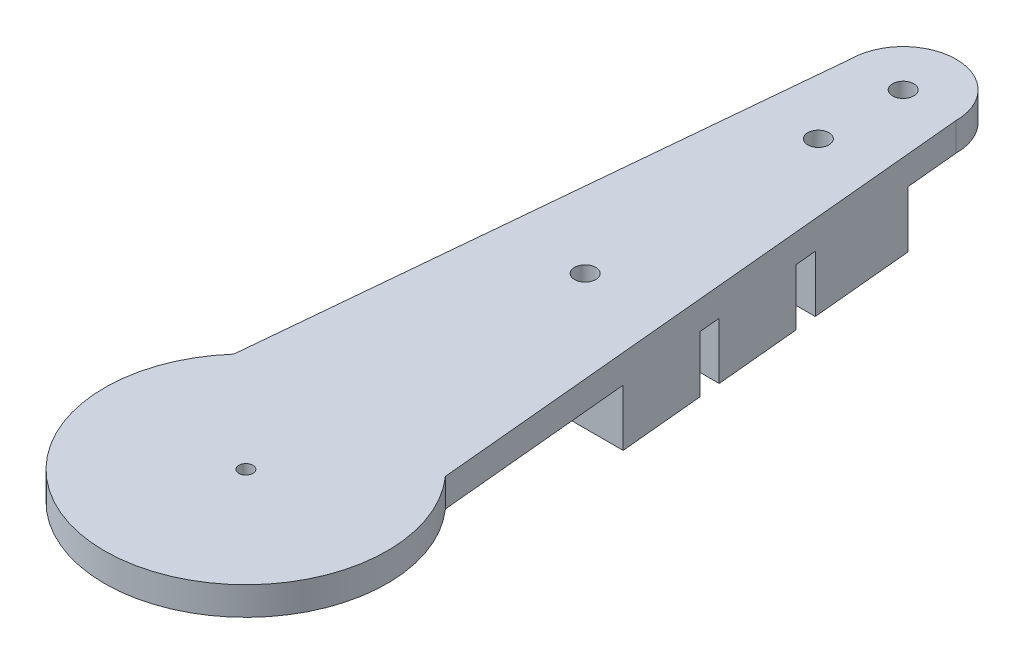
from build123d import *

# Parameters (mm, degrees)
SKETCH2_R           = 1
CUT_EXTRUDE1_DEPTH  = 10
BOSS_EXTRUDE1_DEPTH = 4
BOSS_EXTRUDE2_DEPTH = 8
SKETCH5_R           = 1.5
CUT_EXTRUDE2_DEPTH  = 12
SKETCH6_R           = 7.5
BOSS_EXTRUDE3_DEPTH = 12
CUT_EXTRUDE3_DEPTH  = 8
SKETCH8_R           = 1.5
CUT_EXTRUDE4_DEPTH  = 4


with BuildPart() as part:
    # Sketch1 → Revolve1 (revolve)
    with BuildSketch(Plane.XY):
        Polygon((0, -2), (10.5, -2), (10.5, -4), (20, -4), (20, 0), (0, 0), align=None)
    revolve(axis=Axis((0, 0, 0), (0, -1, 0)))

    # Sketch2 → Cut-Extrude1 (cut)
    with BuildSketch(Plane(origin=(0, 0, 0), x_dir=(1, 0, 0), z_dir=(0, 1, 0))):
        Circle(SKETCH2_R)
    extrude(amount=-CUT_EXTRUDE1_DEPTH, mode=Mode.SUBTRACT)

    # Sketch3 → Boss-Extrude1 (add)
    with BuildSketch(Plane(origin=(0, 0, 0), x_dir=(1, 0, 0), z_dir=(0, 1, 0))):
        Polygon((-7.5, 93), (-15, 13), (15, 13), (7.5, 93), align=None)
    extrude(amount=-BOSS_EXTRUDE1_DEPTH)

    # Sketch4 → Boss-Extrude2 (add)
    with BuildSketch(Plane.XZ.offset(4)):
        Polygon((-12.375, -41), (12.375, -41), (11.25, -53), (-11.25, -53), align=None)
        Polygon((-10.96875, -56), (10.96875, -56), (9.84375, -68), (-9.84375, -68), align=None)
        Polygon((-9.5625, -71), (9.5625, -71), (7.5, -93), (-7.5, -93), align=None)
    extrude(amount=BOSS_EXTRUDE2_DEPTH)

    # Sketch5 → Cut-Extrude2 (cut)
    with BuildSketch(Plane(origin=(0, 0, 0), x_dir=(1, 0, 0), z_dir=(0, 1, 0))):
        with Locations((0, 48)):
            Circle(SKETCH5_R)
        with Locations((0, 81)):
            Circle(SKETCH5_R)
    extrude(amount=-CUT_EXTRUDE2_DEPTH, mode=Mode.SUBTRACT)

    # Sketch6 → Boss-Extrude3 (add)
    with BuildSketch(Plane.XZ.offset(12)):
        with Locations((0, -93)):
            Circle(SKETCH6_R)
    extrude(amount=-BOSS_EXTRUDE3_DEPTH)

    # Sketch7 → Cut-Extrude3 (cut)
    with BuildSketch(Plane.XZ.offset(12)):
        with BuildLine():
            Line((-8.203125, -85.5), (8.203125, -85.5))
            Line((8.203125, -85.5), (7.5, -93))
            ThreePointArc((7.5, -93), (0, -100.5), (-7.5, -93))
            Line((-7.5, -93), (-8.203125, -85.5))
        make_face()
    extrude(amount=-CUT_EXTRUDE3_DEPTH, mode=Mode.SUBTRACT)

    # Sketch8 → Cut-Extrude4 (cut)
    with BuildSketch(Plane(origin=(0, 0, 0), x_dir=(1, 0, 0), z_dir=(0, 1, 0))):
        with Locations((0, 93)):
            Circle(SKETCH8_R)
    extrude(amount=-CUT_EXTRUDE4_DEPTH, mode=Mode.SUBTRACT)


solid = part.part
